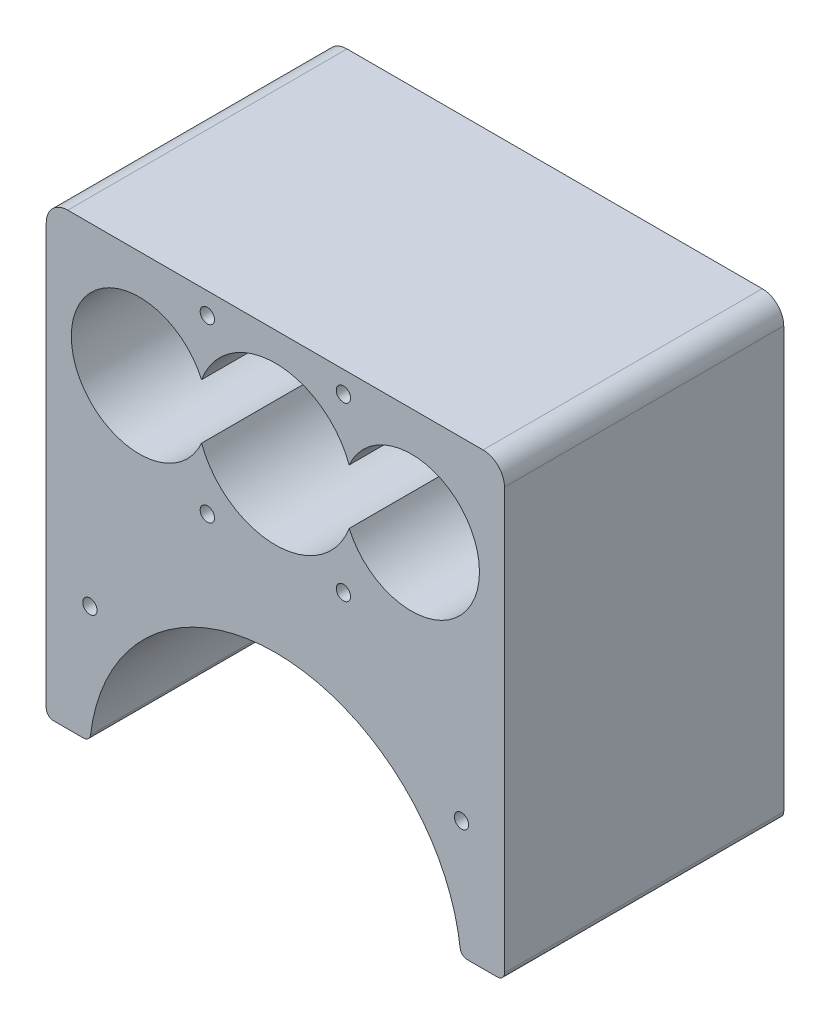
from build123d import *

# Parameters (mm, degrees)
SKETCH_1_R      = 1
EXTRUDE_1_DEPTH = 39


with BuildPart() as part:
    # Эскиз1 → Бобышка-Вытянуть1 (new body)
    with BuildSketch(Plane.XY):
        with BuildLine():
            Line((-32, -17), (-32, 12))
            ThreePointArc((-32, 12), (-31.121320344, 14.121320344), (-29, 15))
            Line((-29, 15), (29, 15))
            ThreePointArc((29, 15), (31.121320344, 14.121320344), (32, 12))
            Line((32, 12), (32, -17))
            Line((32, -17), (32, -46.753646645))
            ThreePointArc((32, -46.753646645), (31.707106781, -47.460753426), (31, -47.753646645))
            Line((31, -47.753646645), (26.804126359, -47.753646645))
            ThreePointArc((26.804126359, -47.753646645), (26.140890093, -47.50205673), (25.811380939, -46.873881955))
            ThreePointArc((25.811380939, -46.873881955), (0, -24), (-25.811380939, -46.873881955))
            ThreePointArc((-25.811380939, -46.873881955), (-26.140890093, -47.50205673), (-26.804126359, -47.753646645))
            Line((-26.804126359, -47.753646645), (-31, -47.753646645))
            ThreePointArc((-31, -47.753646645), (-31.707106781, -47.460753426), (-32, -46.753646645))
            Line((-32, -46.753646645), (-32, -17))
        make_face()
        with Locations((-9.5, 12)):
            Circle(SKETCH_1_R, mode=Mode.SUBTRACT)
        with Locations((9.5, 12)):
            Circle(SKETCH_1_R, mode=Mode.SUBTRACT)
        with Locations((9.5, -12)):
            Circle(SKETCH_1_R, mode=Mode.SUBTRACT)
        with Locations((-9.5, -12)):
            Circle(SKETCH_1_R, mode=Mode.SUBTRACT)
        with Locations((-25.902777778, -31.358962601)):
            Circle(SKETCH_1_R, mode=Mode.SUBTRACT)
        with Locations((26, -31.358962601)):
            Circle(SKETCH_1_R, mode=Mode.SUBTRACT)
        with BuildLine():
            ThreePointArc((-10.309210526, -3.836688458), (0, -11), (10.309210526, -3.836688458))
            ThreePointArc((10.309210526, -3.836688458), (28.5, 0), (10.309210526, 3.836688458))
            ThreePointArc((10.309210526, 3.836688458), (0, 11), (-10.309210526, 3.836688458))
            ThreePointArc((-10.309210526, 3.836688458), (-28.5, 0), (-10.309210526, -3.836688458))
        make_face(mode=Mode.SUBTRACT)
    extrude(amount=EXTRUDE_1_DEPTH)


solid = part.part
